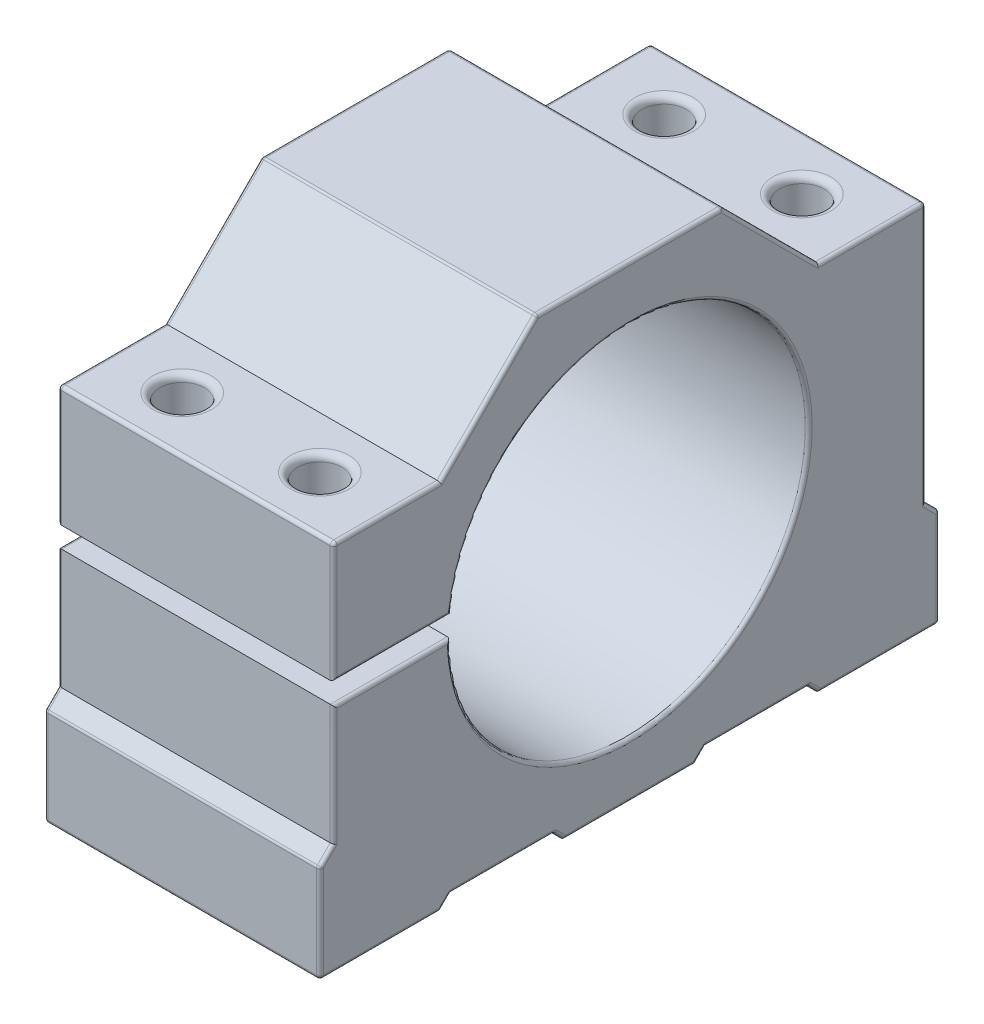
from build123d import *

# Parameters (mm, degrees)
EXTRUDE_1_DEPTH     = 40
SKETCH_3_R          = 26
SKETCH_3_W          = 34.254870362
SKETCH_3_H          = 3
CUT_EXTRUDE_1_DEPTH = 40
SKETCH_5_R          = 3.25
CUT_EXTRUDE_2_DEPTH = 69
FILLET_1_R          = 1
CUT_EXTRUDE_3_DEPTH = 40
FILLET_2_R          = 0.5


with BuildPart() as part:
    # Эскиз1 → Бобышка-Вытянуть1 (new body)
    with BuildSketch(Plane(origin=(0, 0, 0), x_dir=(0, 0, -1), z_dir=(1, 0, 0))):
        Polygon((0, 0), (90, 0), (90, 14.142135624), (88, 16.142135624), (88, 54), (72.5, 54), (58.5, 68), (31.5, 68), (17.5, 54), (2, 54), (2, 16.142135624), (0, 14.142135624), align=None)
    extrude(amount=EXTRUDE_1_DEPTH)

    # Эскиз3 → Вырез-Вытянуть1 (cut)
    with BuildSketch(Plane.ZY):
        with Locations((-45, 34)):
            Circle(SKETCH_3_R)
        with Locations((-2, 35.071067812)):
            Rectangle(SKETCH_3_W, SKETCH_3_H)
    extrude(amount=-CUT_EXTRUDE_1_DEPTH, mode=Mode.SUBTRACT)

    # Эскиз5 → Вырез-Вытянуть2 (cut, through all)
    with BuildSketch(Plane.XZ):
        with Locations((10, -10)):
            Circle(SKETCH_5_R)
        with Locations((30, -10)):
            Circle(SKETCH_5_R)
        with Locations((10, -80)):
            Circle(SKETCH_5_R)
        with Locations((30, -80)):
            Circle(SKETCH_5_R)
    extrude(amount=-CUT_EXTRUDE_2_DEPTH, mode=Mode.SUBTRACT)

    # Скругление1
    fillet_1_edges = [part.edges().sort_by_distance(p)[0] for p in [
        (6.75, 54, -10),
        (26.75, 54, -10),
        (6.75, 54, -80),
        (26.75, 54, -80),
    ]]
    fillet(fillet_1_edges, radius=FILLET_1_R)

    # Эскиз6 → Вырез-Вытянуть3 (cut)
    with BuildSketch(Plane.ZY):
        Polygon((-19, 1.5), (-34, 1.5), (-35.5, 0), (-17.5, 0), align=None)
        Polygon((-71, 1.5), (-56, 1.5), (-54.5, 0), (-72.5, 0), align=None)
    extrude(amount=-CUT_EXTRUDE_3_DEPTH, mode=Mode.SUBTRACT)

    # Скругление2
    fillet_2_edges = [part.edges().sort_by_distance(p)[0] for p in [
        (40, 7.071067812, -90),
        (0, 0, -81.25),
        (40, 0, -81.25),
        (0, 15.142135624, -1),
        (0, 0.75, -71.75),
        (0, 1.5, -63.5),
        (0, 0.75, -55.25),
        (40, 0.75, -71.75),
        (0, 45.285533906, -2),
        (40, 1.5, -63.5),
        (40, 0.75, -55.25),
        (0, 54, -9.75),
        (0, 61, -24.5),
        (0, 68, -45),
        (0, 61, -65.5),
        (40, 15.142135624, -89),
        (0, 54, -80.25),
        (0, 35.071067812, -88),
        (0, 15.142135624, -89),
        (0, 7.071067812, -90),
        (0, 0, -8.75),
        (0, 7.071067812, 0),
        (40, 35.071067812, -88),
        (40, 54, -80.25),
        (20, 14.142135624, 0),
        (20, 54, -2),
        (20, 68, -31.5),
        (20, 68, -58.5),
        (20, 54, -88),
        (20, 14.142135624, -90),
        (20, 0, -90),
        (20, 0, 0),
        (40, 61, -65.5),
        (40, 68, -45),
        (40, 61, -24.5),
        (40, 54, -9.75),
        (0, 24.856601718, -2),
        (0, 36.571067812, -10.563717591),
        (40, 45.285533906, -2),
        (0, 33.571067812, -10.501769186),
        (40, 24.856601718, -2),
        (40, 15.142135624, -1),
        (0, 32.927142198, -70.977855495),
        (40, 33.571067812, -10.501769186),
        (40, 36.571067812, -10.563717591),
        (40, 7.071067812, 0),
        (40, 32.927142198, -70.977855495),
        (40, 0, -8.75),
        (0, 0, -45),
        (40, 0, -45),
        (40, 0.75, -34.75),
        (40, 1.5, -26.5),
        (20, 1.5, -34),
        (40, 0.75, -18.25),
        (20, 1.5, -19),
        (0, 0.75, -18.25),
        (0, 1.5, -26.5),
        (0, 0.75, -34.75),
    ]]
    fillet(fillet_2_edges, radius=FILLET_2_R)


solid = part.part
